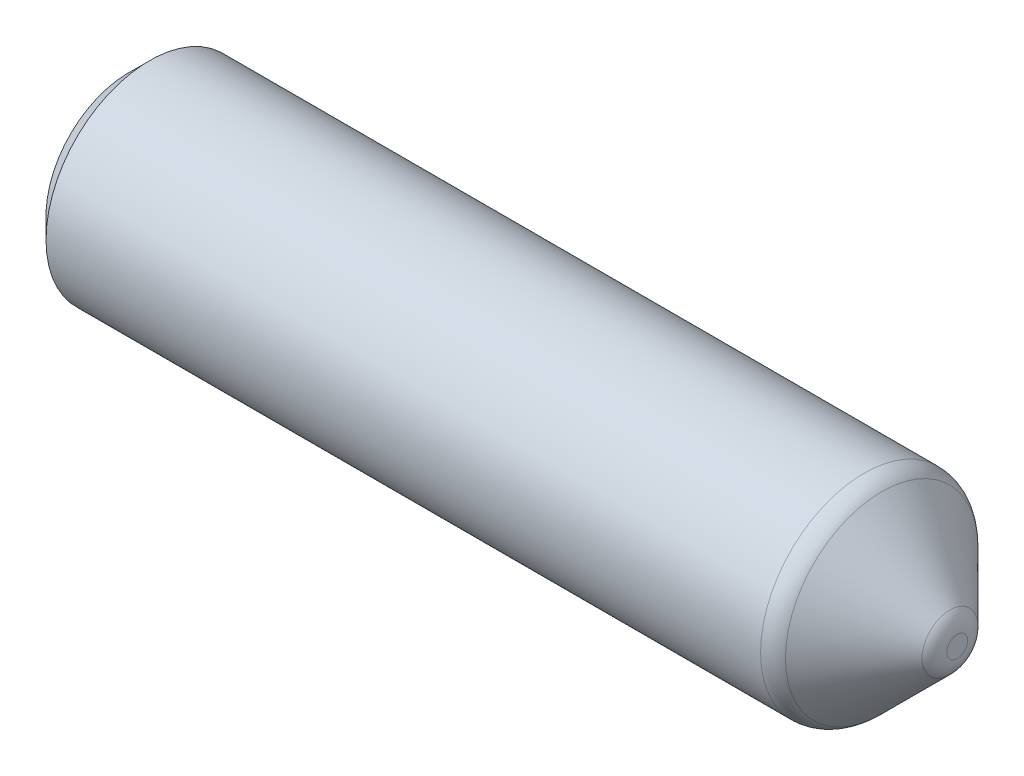
from build123d import *

# Parameters (mm, degrees)
SKETCH1_R           = 50
BOSS_EXTRUDE1_DEPTH = 200
CHAMFER1_SIZE       = 40
FILLET1_R           = 12
FILLET2_R           = 12
CHAMFER2_SIZE       = 10


with BuildPart() as part:
    # Sketch1 → Boss-Extrude1 (new body, symmetric)
    with BuildSketch(Plane(origin=(0, 0, 0), x_dir=(0, 0, -1), z_dir=(1, 0, 0))):
        Circle(SKETCH1_R)
    extrude(amount=BOSS_EXTRUDE1_DEPTH, both=True)

    # Chamfer1
    chamfer1_edges = [part.edges().sort_by_distance(p)[0] for p in [
        (200, 0, 50),
    ]]
    chamfer(chamfer1_edges, length=CHAMFER1_SIZE)

    # Fillet1
    fillet1_edges = [part.edges().sort_by_distance(p)[0] for p in [
        (200, 0, 10),
    ]]
    fillet(fillet1_edges, radius=FILLET1_R)

    # Fillet2
    fillet2_edges = [part.edges().sort_by_distance(p)[0] for p in [
        (160, 0, 50),
    ]]
    fillet(fillet2_edges, radius=FILLET2_R)

    # Chamfer2
    chamfer2_edges = [part.edges().sort_by_distance(p)[0] for p in [
        (-200, 0, 50),
    ]]
    chamfer(chamfer2_edges, length=CHAMFER2_SIZE)


solid = part.part
